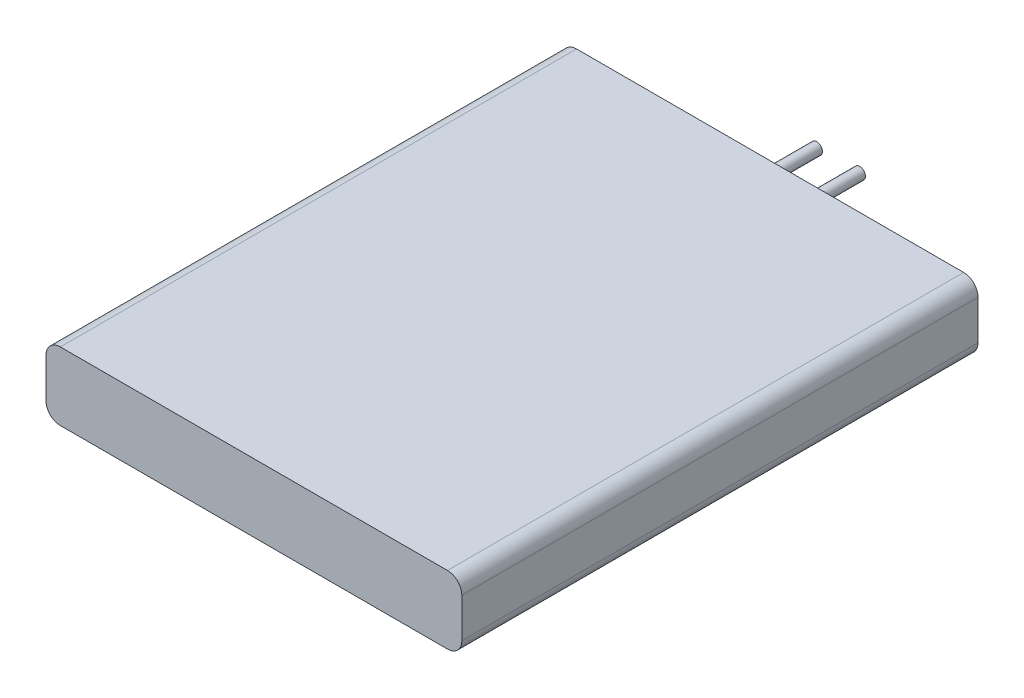
from build123d import *

# Parameters (mm, degrees)
SKETCH1_W           = 29
SKETCH1_H           = 36
BOSS_EXTRUDE1_DEPTH = 4.75
SKETCH2_R           = 0.4
BOSS_EXTRUDE2_DEPTH = 4.75
FILLET1_R           = 1


with BuildPart() as part:
    # Sketch1 → Boss-Extrude1 (new body)
    with BuildSketch(Plane(origin=(0, 0, 0), x_dir=(1, 0, 0), z_dir=(0, 1, 0))):
        Rectangle(SKETCH1_W, SKETCH1_H)
    extrude(amount=BOSS_EXTRUDE1_DEPTH)

    # Sketch2 → Boss-Extrude2 (add)
    with BuildSketch(Plane(origin=(0, 0, -18), x_dir=(-1, 0, 0), z_dir=(0, 0, -1))):
        with Locations((1.5, 2.375)):
            Circle(SKETCH2_R)
        with Locations((-1.5, 2.375)):
            Circle(SKETCH2_R)
    extrude(amount=BOSS_EXTRUDE2_DEPTH)

    # Fillet1
    fillet1_edges = [part.edges().sort_by_distance(p)[0] for p in [
        (-14.5, 4.75, 0),
        (14.5, 4.75, 0),
        (-14.5, 0, 0),
        (14.5, 0, 0),
    ]]
    fillet(fillet1_edges, radius=FILLET1_R)


solid = part.part
